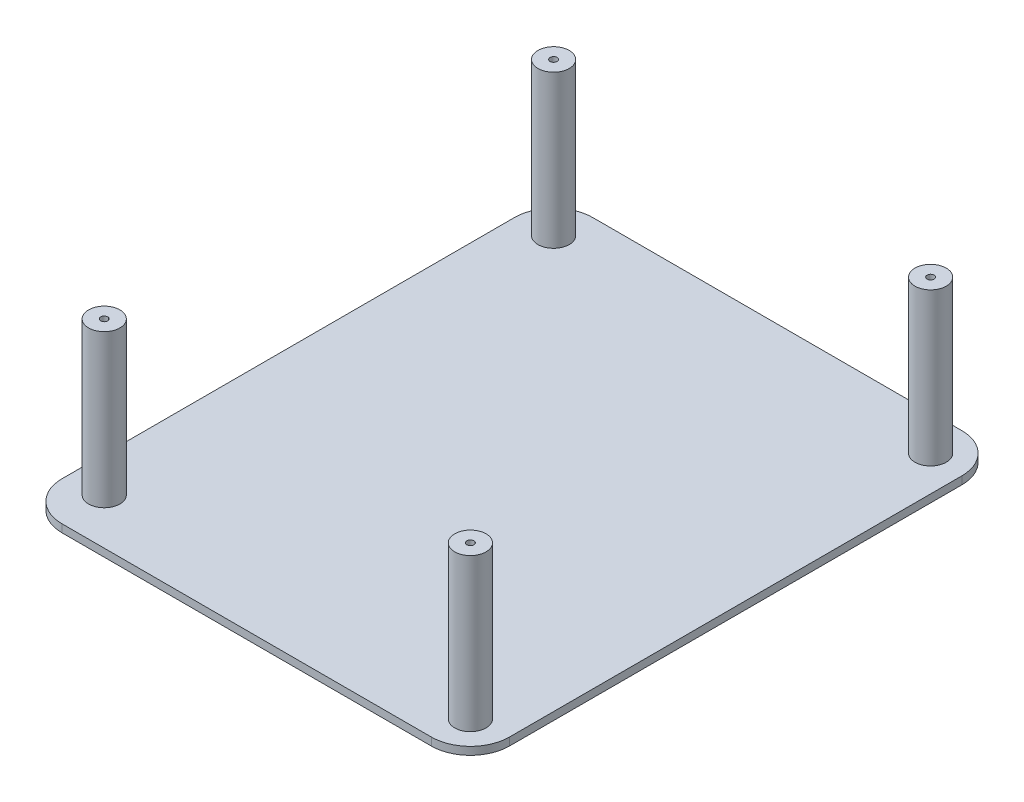
from build123d import *

# Parameters (mm, degrees)
SKETCH_1_W          = 114.397193433
SKETCH_1_H          = 135.669398824
EXTRUDE_1_DEPTH     = 2
SKETCH_2_R          = 4
EXTRUDE_2_DEPTH     = 39
SKETCH_3_R          = 0.9
CUT_EXTRUDE_1_DEPTH = 11
FILLET_1_R          = 10


with BuildPart() as part:
    # Эскиз1 → Бобышка-Вытянуть1 (new body)
    with BuildSketch(Plane(origin=(0, 0, 0), x_dir=(1, 0, 0), z_dir=(0, 1, 0))):
        with Locations((-0.236357837, -15.24508053)):
            Rectangle(SKETCH_1_W, SKETCH_1_H)
    extrude(amount=EXTRUDE_1_DEPTH)

    # Эскиз2 → Бобышка-Вытянуть2 (add)
    with BuildSketch(Plane(origin=(0, 2, 0), x_dir=(1, 0, 0), z_dir=(0, 1, 0))):
        with Locations((-48.434954554, 43.589618882)):
            Circle(SKETCH_2_R)
        with Locations((47.962238879, 43.589618882)):
            Circle(SKETCH_2_R)
        with Locations((47.962238879, -74.079779942)):
            Circle(SKETCH_2_R)
        with Locations((-48.434954554, -71.306708374)):
            Circle(SKETCH_2_R)
    extrude(amount=EXTRUDE_2_DEPTH)

    # Эскиз3 → Вырез-Вытянуть1 (cut)
    with BuildSketch(Plane(origin=(0, 41, 0), x_dir=(1, 0, 0), z_dir=(0, 1, 0))):
        with Locations((47.962238879, -74.079779942)):
            Circle(SKETCH_3_R)
        with Locations((-48.434954554, -71.306708374)):
            Circle(SKETCH_3_R)
        with Locations((-48.434954554, 43.589618882)):
            Circle(SKETCH_3_R)
        with Locations((47.962238879, 43.589618882)):
            Circle(SKETCH_3_R)
    extrude(amount=-CUT_EXTRUDE_1_DEPTH, mode=Mode.SUBTRACT)

    # Скругление1
    fillet_1_edges = [part.edges().sort_by_distance(p)[0] for p in [
        (-57.434954554, 1, -52.589618882),
        (56.962238879, 1, -52.589618882),
        (56.962238879, 1, 83.079779942),
        (-57.434954554, 1, 83.079779942),
    ]]
    fillet(fillet_1_edges, radius=FILLET_1_R)


solid = part.part
